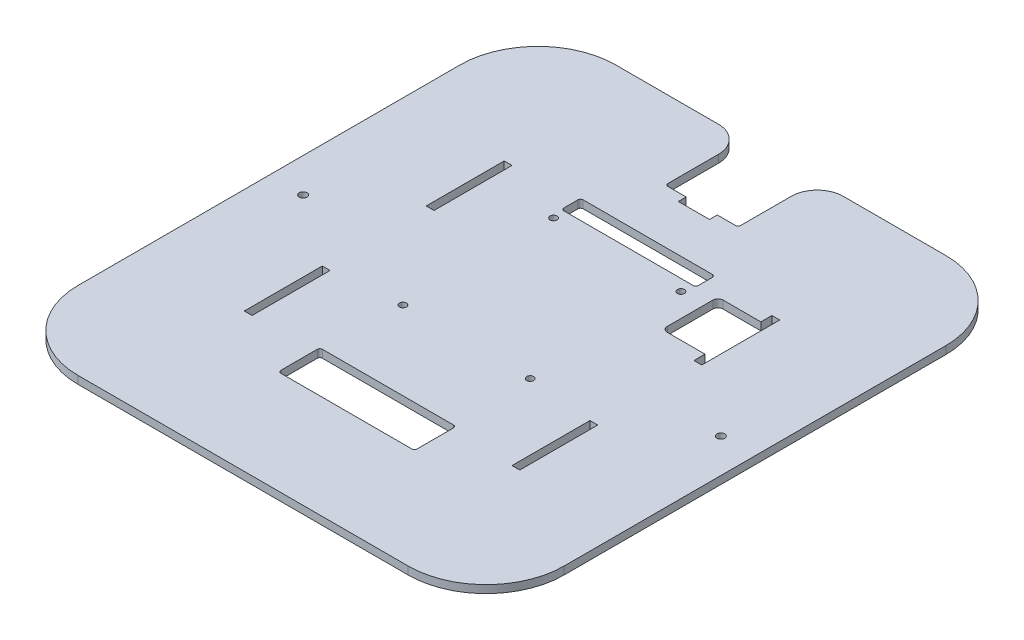
from build123d import *
from OCP.BRepFilletAPI import BRepFilletAPI_MakeFillet

# Parameters (mm, degrees)
SKETCH1_W                = 187
SKETCH1_H                = 206.9
BOSS_EXTRUDE1_DEPTH      = 1.5
FILLET1_R                = 30
CUT_EXTRUDE1_DEPTH       = 140.450358551
CUT_EXTRUDE1_DEPTH_BACK  = 140.450358551
SKETCH2_W                = 3
SKETCH2_H                = 30
CUT_EXTRUDE3_DEPTH       = 140.474558612
CUT_EXTRUDE3_DEPTH_BACK  = 140.474558612
SKETCH4_R                = 1.35
CUT_EXTRUDE2_DEPTH       = 140.474558612
CUT_EXTRUDE5_DEPTH       = 140.474558612
CUT_EXTRUDE5_DEPTH_BACK  = 140.474558612
CUT_EXTRUDE6_DEPTH       = 140.450358551
CUT_EXTRUDE6_DEPTH_BACK  = 140.450358551
CUT_EXTRUDE9_DEPTH       = 140.450358551
CUT_EXTRUDE9_DEPTH_BACK  = 140.450358551
SKETCH10_R               = 1.5
CUT_EXTRUDE10_DEPTH      = 140.474558612
CUT_EXTRUDE10_DEPTH_BACK = 140.474558612
SKETCH11_W               = 28
SKETCH11_H               = 30.45294386
FILLET2_R1               = 10
FILLET2_R2               = 1
CUT_EXTRUDE11_DEPTH      = 140.450358551
CUT_EXTRUDE11_DEPTH_BACK = 140.450358551
SKETCH12_W               = 12
SKETCH12_H               = 3


with BuildPart() as part:
    # Sketch1 → Boss-Extrude1 (new, symmetric)
    with BuildSketch(Plane(origin=(0, 0, 0), x_dir=(1, 0, 0), z_dir=(0, 1, 0))):
        Rectangle(SKETCH1_W, SKETCH1_H)
    extrude(amount=BOSS_EXTRUDE1_DEPTH, both=True)

    # Fillet1
    fillet1_edges = [part.edges().sort_by_distance(p)[0] for p in [
        (93.5, 0, -103.45),
        (93.5, 0, 103.45),
        (-93.5, 0, 103.45),
        (-93.5, 0, -103.45),
    ]]
    fillet(fillet1_edges, radius=FILLET1_R)

    # Sketch2 → Cut-Extrude1 (cut, two sides: drawn at the far end of the back side and taken through both)
    with BuildSketch(Plane(origin=(0, 0, 0), x_dir=(1, 0, 0), z_dir=(0, 1, 0)).offset(-CUT_EXTRUDE1_DEPTH_BACK)):
        with Locations((-51.5, 35)):
            Rectangle(SKETCH2_W, SKETCH2_H)
        with Locations((-51.5, -35)):
            Rectangle(SKETCH2_W, SKETCH2_H)
        with Locations((51.5, -35)):
            Rectangle(SKETCH2_W, SKETCH2_H)
        with Locations((51.5, 35)):
            Rectangle(SKETCH2_W, SKETCH2_H)
    extrude(amount=CUT_EXTRUDE1_DEPTH + CUT_EXTRUDE1_DEPTH_BACK, mode=Mode.SUBTRACT)

    # Sketch4 → Cut-Extrude3 (cut, two sides: drawn at the far end of the back side and taken through both)
    with BuildSketch(Plane(origin=(0, 1.5, 0), x_dir=(1, 0, 0), z_dir=(0, 1, 0)).offset(-CUT_EXTRUDE3_DEPTH_BACK)):
        with Locations((24.5, -17.5)):
            Circle(SKETCH4_R)
        with Locations((-24.5, -17.5)):
            Circle(SKETCH4_R)
        with Locations((24.5, 40.5)):
            Circle(SKETCH4_R)
        with Locations((-24.5, 40.5)):
            Circle(SKETCH4_R)
    extrude(amount=CUT_EXTRUDE3_DEPTH + CUT_EXTRUDE3_DEPTH_BACK, mode=Mode.SUBTRACT)

    # Sketch3 → Cut-Extrude2 (cut, through all)
    with BuildSketch(Plane(origin=(0, 1.5, 0), x_dir=(1, 0, 0), z_dir=(0, 1, 0))):
        with BuildLine():
            Line((50, 45.75), (50, 24.25))
            Line((50, 24.25), (35.5, 24.25))
            ThreePointArc((35.5, 24.25), (34.085786438, 24.835786438), (33.5, 26.25))
            Line((33.5, 26.25), (33.5, 43.75))
            ThreePointArc((33.5, 43.75), (34.085786438, 45.164213562), (35.5, 45.75))
            Line((35.5, 45.75), (50, 45.75))
        make_face()
    extrude(amount=-CUT_EXTRUDE2_DEPTH, mode=Mode.SUBTRACT)

    # Sketch6 → Cut-Extrude5 (cut, two sides: drawn at the far end of the back side and taken through both)
    with BuildSketch(Plane(origin=(0, 1.5, 0), x_dir=(1, 0, 0), z_dir=(0, 1, 0)).offset(-CUT_EXTRUDE5_DEPTH_BACK)):
        with BuildLine():
            Line((-25.2, -47.73), (25.2, -47.73))
            ThreePointArc((25.2, -47.73), (25.907106781, -48.022893219), (26.2, -48.73))
            Line((26.2, -48.73), (26.2, -62.73))
            ThreePointArc((26.2, -62.73), (25.907106781, -63.437106781), (25.2, -63.73))
            Line((25.2, -63.73), (-25.2, -63.73))
            ThreePointArc((-25.2, -63.73), (-25.907106781, -63.437106781), (-26.2, -62.73))
            Line((-26.2, -62.73), (-26.2, -48.73))
            ThreePointArc((-26.2, -48.73), (-25.907106781, -48.022893219), (-25.2, -47.73))
        make_face()
    extrude(amount=CUT_EXTRUDE5_DEPTH + CUT_EXTRUDE5_DEPTH_BACK, mode=Mode.SUBTRACT)

    # Sketch7 → Cut-Extrude6 (cut, two sides: drawn at the far end of the back side and taken through both)
    with BuildSketch(Plane(origin=(0, 0, 0), x_dir=(1, 0, 0), z_dir=(0, 1, 0)).offset(-CUT_EXTRUDE6_DEPTH_BACK)):
        with BuildLine():
            Line((-24.85, 52.23), (24.85, 52.23))
            ThreePointArc((24.85, 52.23), (25.557106781, 51.937106781), (25.85, 51.23))
            Line((25.85, 51.23), (25.85, 45.85))
            ThreePointArc((25.85, 45.85), (25.557106781, 45.142893219), (24.85, 44.85))
            Line((24.85, 44.85), (-24.85, 44.85))
            ThreePointArc((-24.85, 44.85), (-25.557106781, 45.142893219), (-25.85, 45.85))
            Line((-25.85, 45.85), (-25.85, 51.23))
            ThreePointArc((-25.85, 51.23), (-25.557106781, 51.937106781), (-24.85, 52.23))
        make_face()
    extrude(amount=CUT_EXTRUDE6_DEPTH + CUT_EXTRUDE6_DEPTH_BACK, mode=Mode.SUBTRACT)

    # Sketch10 → Cut-Extrude9 (cut, two sides: drawn at the far end of the back side and taken through both)
    with BuildSketch(Plane(origin=(0, 0, 0), x_dir=(1, 0, 0), z_dir=(0, 1, 0)).offset(-CUT_EXTRUDE9_DEPTH_BACK)):
        with Locations((-80.35, 0)):
            Circle(SKETCH10_R)
        with Locations((80.35, 0)):
            Circle(SKETCH10_R)
    extrude(amount=CUT_EXTRUDE9_DEPTH + CUT_EXTRUDE9_DEPTH_BACK, mode=Mode.SUBTRACT)

    # Sketch11 → Cut-Extrude10 (cut, two sides: drawn at the far end of the back side and taken through both)
    with BuildSketch(Plane(origin=(0, 1.5, 0), x_dir=(1, 0, 0), z_dir=(0, 1, 0)).offset(-CUT_EXTRUDE10_DEPTH_BACK)):
        with Locations((0, 88.22352807)):
            Rectangle(SKETCH11_W, SKETCH11_H)
    extrude(amount=CUT_EXTRUDE10_DEPTH + CUT_EXTRUDE10_DEPTH_BACK, mode=Mode.SUBTRACT)

    # Fillet2: one fillet with a radius per group of edges: ONE call of the kernel's fillet builder (fillet() takes one radius for all edges)
    fillet2_edges_1 = [part.edges().sort_by_distance(p)[0] for p in [
        (-14, 0, -103.45),
        (14, 0, -103.45),
    ]]
    fillet2_edges_2 = [part.edges().sort_by_distance(p)[0] for p in [
        (-14, 0, -72.99705614),
        (14, 0, -72.99705614),
    ]]
    fillet2 = BRepFilletAPI_MakeFillet(part.part.solid().wrapped)
    for e in fillet2_edges_1:
        fillet2.Add(FILLET2_R1, e.wrapped)
    for e in fillet2_edges_2:
        fillet2.Add(FILLET2_R2, e.wrapped)
    add(Compound.cast(fillet2.Shape()), mode=Mode.REPLACE)

    # Sketch12 → Cut-Extrude11 (cut, two sides: drawn at the far end of the back side and taken through both)
    with BuildSketch(Plane(origin=(0, 0, 0), x_dir=(1, 0, 0), z_dir=(0, 1, 0)).offset(-CUT_EXTRUDE11_DEPTH_BACK)):
        with Locations((0, 71.49705614)):
            Rectangle(SKETCH12_W, SKETCH12_H)
    extrude(amount=CUT_EXTRUDE11_DEPTH + CUT_EXTRUDE11_DEPTH_BACK, mode=Mode.SUBTRACT)


solid = part.part
